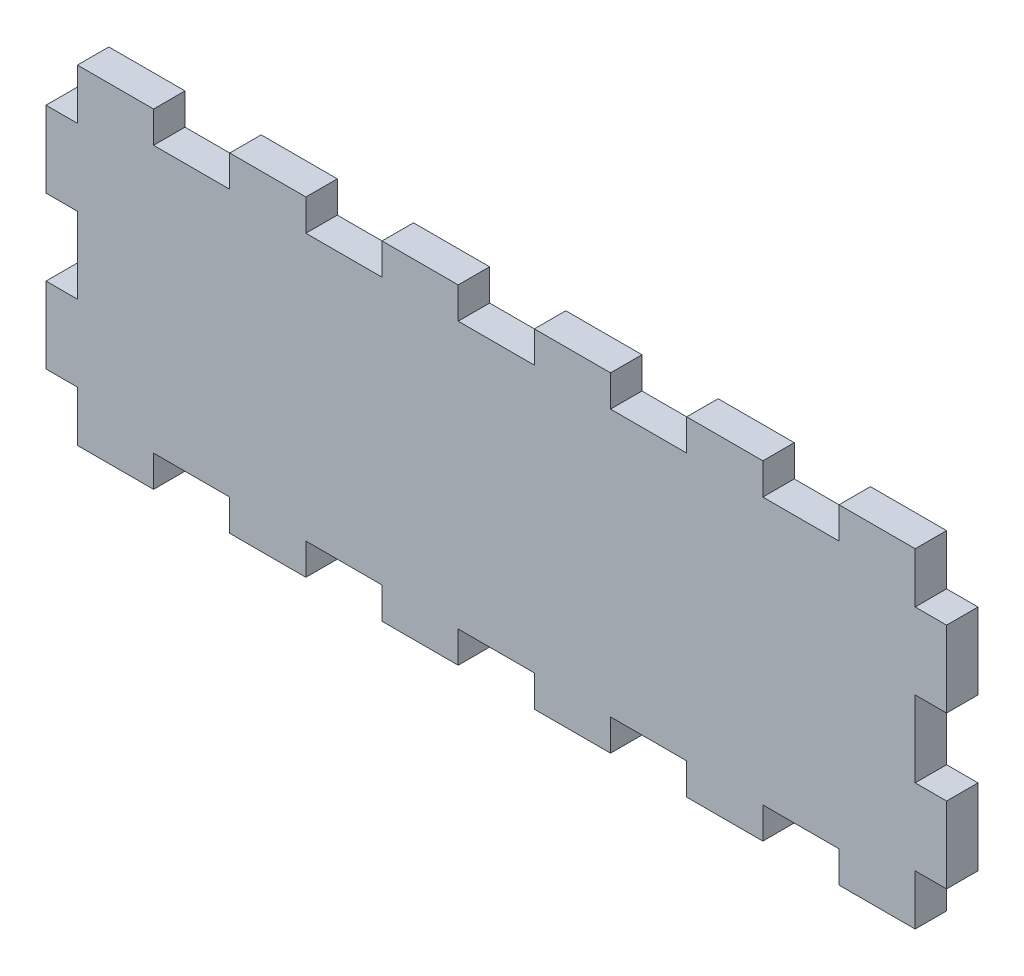
from build123d import *

# Parameters (mm, degrees)
ESQUISSE1_W                    = 94.6
ESQUISSE1_H                    = 28
BOSS_EXTRU_1_DEPTH             = 3.3
ESQUISSE2_W                    = 8
ESQUISSE2_H                    = 3.3
BOSS_EXTRU_2_DEPTH             = 3.3
R_P_TITION_LIN_AIRE1_COUNT     = 3
R_P_TITION_LIN_AIRE1_PITCH     = 16
R_P_TITION_LIN_AIRE1_COL_COUNT = 4
R_P_TITION_LIN_AIRE1_COL_PITCH = 16
SYM_TRIE1_COPY_1_SKETCH_W      = 8
SYM_TRIE1_COPY_1_SKETCH_H      = 3.3
SYM_TRIE1_COPY_1_DEPTH         = 3.3
SYM_TRIE1_COPY_2_SKETCH_W      = 8
SYM_TRIE1_COPY_2_SKETCH_H      = 3.3
SYM_TRIE1_COPY_2_DEPTH         = 3.3
SYM_TRIE1_COPY_3_SKETCH_W      = 8
SYM_TRIE1_COPY_3_SKETCH_H      = 3.3
SYM_TRIE1_COPY_3_DEPTH         = 3.3
SYM_TRIE1_COPY_4_SKETCH_W      = 8
SYM_TRIE1_COPY_4_SKETCH_H      = 3.3
SYM_TRIE1_COPY_4_DEPTH         = 3.3
SYM_TRIE1_COPY_5_SKETCH_W      = 8
SYM_TRIE1_COPY_5_SKETCH_H      = 3.3
SYM_TRIE1_COPY_5_DEPTH         = 3.3
ESQUISSE3_W                    = 3.3
ESQUISSE3_H                    = 8
ESQUISSE3_H_2                  = 2
ENL_V_MAT_EXTRU_1_DEPTH        = 3.3


with BuildPart() as part:
    # Esquisse1 → Boss.-Extru.1 (new body)
    with BuildSketch(Plane.XY):
        Rectangle(ESQUISSE1_W, ESQUISSE1_H)
    extrude(amount=BOSS_EXTRU_1_DEPTH)

    # Esquisse2 → Boss.-Extru.2 (add)
    with BuildSketch(Plane(origin=(0, 0, 0), x_dir=(-1, 0, 0), z_dir=(0, 0, -1))):
        with Locations((8, 15.65)):
            Rectangle(ESQUISSE2_W, ESQUISSE2_H)
    boss_extru_2 = extrude(amount=-BOSS_EXTRU_2_DEPTH)

    # Répétition linéaire1: Boss.-Extru.2 ×3
    with Locations(*[(-i * R_P_TITION_LIN_AIRE1_PITCH, 0, 0) for i in range(1, R_P_TITION_LIN_AIRE1_COUNT)]):
        add(boss_extru_2)

    # Répétition linéaire1 col: Boss.-Extru.2 ×4
    with Locations(*[(i * R_P_TITION_LIN_AIRE1_COL_PITCH, 0, 0) for i in range(1, R_P_TITION_LIN_AIRE1_COL_COUNT)]):
        add(boss_extru_2)

    # Symétrie1: Boss.-Extru.2 across plane
    add(boss_extru_2.mirror(Plane.ZX))

    # Symétrie1 copy 1 sketch → Symétrie1 copy 1 (add)
    with BuildSketch(Plane(origin=(-16, 0, 0), x_dir=(-1, 0, 0), z_dir=(0, 0, -1))):
        with Locations((8, -15.65)):
            Rectangle(SYM_TRIE1_COPY_1_SKETCH_W, SYM_TRIE1_COPY_1_SKETCH_H)
    extrude(amount=-SYM_TRIE1_COPY_1_DEPTH)

    # Symétrie1 copy 2 sketch → Symétrie1 copy 2 (add)
    with BuildSketch(Plane(origin=(-32, 0, 0), x_dir=(-1, 0, 0), z_dir=(0, 0, -1))):
        with Locations((8, -15.65)):
            Rectangle(SYM_TRIE1_COPY_2_SKETCH_W, SYM_TRIE1_COPY_2_SKETCH_H)
    extrude(amount=-SYM_TRIE1_COPY_2_DEPTH)

    # Symétrie1 copy 3 sketch → Symétrie1 copy 3 (add)
    with BuildSketch(Plane(origin=(16, 0, 0), x_dir=(-1, 0, 0), z_dir=(0, 0, -1))):
        with Locations((8, -15.65)):
            Rectangle(SYM_TRIE1_COPY_3_SKETCH_W, SYM_TRIE1_COPY_3_SKETCH_H)
    extrude(amount=-SYM_TRIE1_COPY_3_DEPTH)

    # Symétrie1 copy 4 sketch → Symétrie1 copy 4 (add)
    with BuildSketch(Plane(origin=(32, 0, 0), x_dir=(-1, 0, 0), z_dir=(0, 0, -1))):
        with Locations((8, -15.65)):
            Rectangle(SYM_TRIE1_COPY_4_SKETCH_W, SYM_TRIE1_COPY_4_SKETCH_H)
    extrude(amount=-SYM_TRIE1_COPY_4_DEPTH)

    # Symétrie1 copy 5 sketch → Symétrie1 copy 5 (add)
    with BuildSketch(Plane(origin=(48, 0, 0), x_dir=(-1, 0, 0), z_dir=(0, 0, -1))):
        with Locations((8, -15.65)):
            Rectangle(SYM_TRIE1_COPY_5_SKETCH_W, SYM_TRIE1_COPY_5_SKETCH_H)
    extrude(amount=-SYM_TRIE1_COPY_5_DEPTH)

    # Esquisse3 → Enlèv. mat.-Extru.1 (cut)
    with BuildSketch(Plane(origin=(0, 0, 0), x_dir=(-1, 0, 0), z_dir=(0, 0, -1))):
        with Locations((-45.65, 0)):
            Rectangle(ESQUISSE3_W, ESQUISSE3_H)
        with Locations((-45.65, 13)):
            Rectangle(ESQUISSE3_W, ESQUISSE3_H_2)
        with Locations((-45.65, -13)):
            Rectangle(ESQUISSE3_W, ESQUISSE3_H_2)
    enl_v_mat_extru_1 = extrude(amount=-ENL_V_MAT_EXTRU_1_DEPTH, mode=Mode.SUBTRACT)

    # Symétrie2: Enlèv. mat.-Extru.1 across plane
    add(enl_v_mat_extru_1.mirror(Plane(origin=(0, 0, 0), x_dir=(0, 0, 1), z_dir=(1, 0, 0))), mode=Mode.SUBTRACT)


solid = part.part
